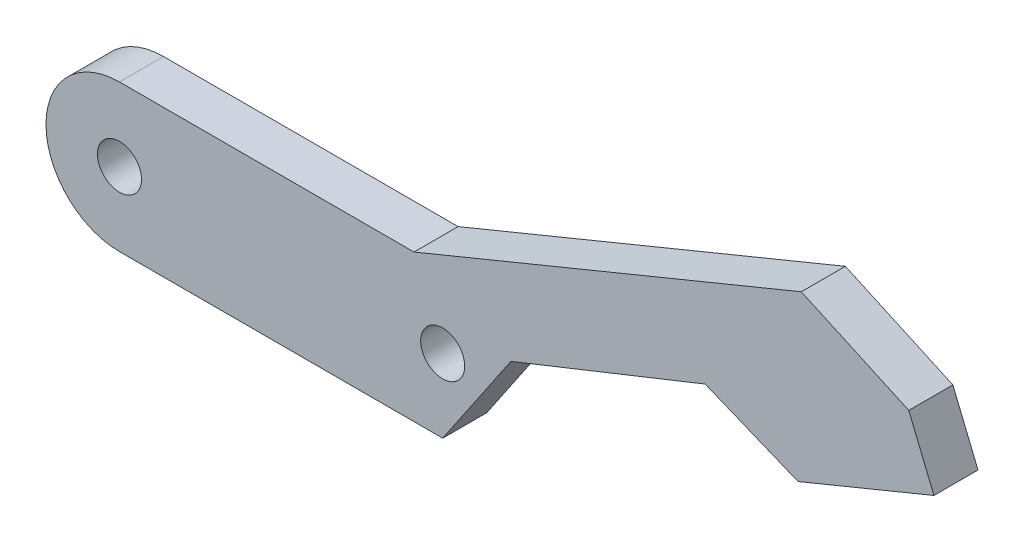
from build123d import *

# Parameters (mm, degrees)
SKETCH_1_R      = 1.5
EXTRUDE_1_DEPTH = 3


with BuildPart() as part:
    # 草图1 → 凸台-拉伸1 (new body)
    with BuildSketch(Plane.XY):
        with BuildLine():
            Line((20.05, 5), (0, 5))
            ThreePointArc((0, 5), (-5, 0), (0, -5))
            Line((0, -5), (22, -5))
            Line((22, -5), (26.644435765, 1.851814361))
            Line((26.644435765, 1.851814361), (39.871788822, 7.125781662))
            Line((39.871788822, 7.125781662), (46.188488025, 4.540007042))
            Line((46.188488025, 4.540007042), (55.437270307, 8.34264117))
            Line((55.437270307, 8.34264117), (53.72608495, 12.504593197))
            Line((53.72608495, 12.504593197), (46.409029503, 15.837507263))
            Line((46.409029503, 15.837507263), (20.05, 5))
        make_face()
        Circle(SKETCH_1_R, mode=Mode.SUBTRACT)
        with Locations((22, 0)):
            Circle(SKETCH_1_R, mode=Mode.SUBTRACT)
    extrude(amount=EXTRUDE_1_DEPTH)


solid = part.part
